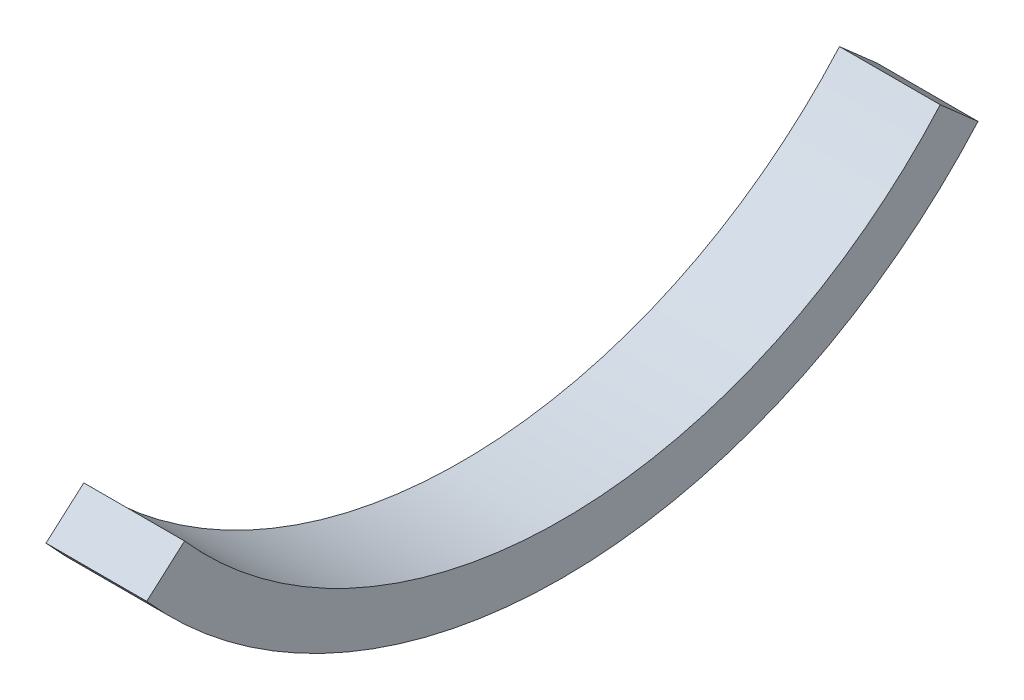
from build123d import *

# Parameters (mm, degrees)
BOSS_EXTRUDE1_DEPTH = 5.08


with BuildPart() as part:
    # Sketch1 → Boss-Extrude1 (new body)
    with BuildSketch(Plane(origin=(0, 0, 0), x_dir=(0, 0, -1), z_dir=(1, 0, 0))):
        with BuildLine():
            Line((20.955, -18.480572908), (19.05, -16.800520825))
            ThreePointArc((19.05, -16.800520825), (0, -25.4), (-19.05, -16.800520825))
            Line((-19.05, -16.800520825), (-20.955, -18.480572908))
            ThreePointArc((-20.955, -18.480572908), (0, -27.94), (20.955, -18.480572908))
        make_face()
    extrude(amount=BOSS_EXTRUDE1_DEPTH)


solid = part.part
